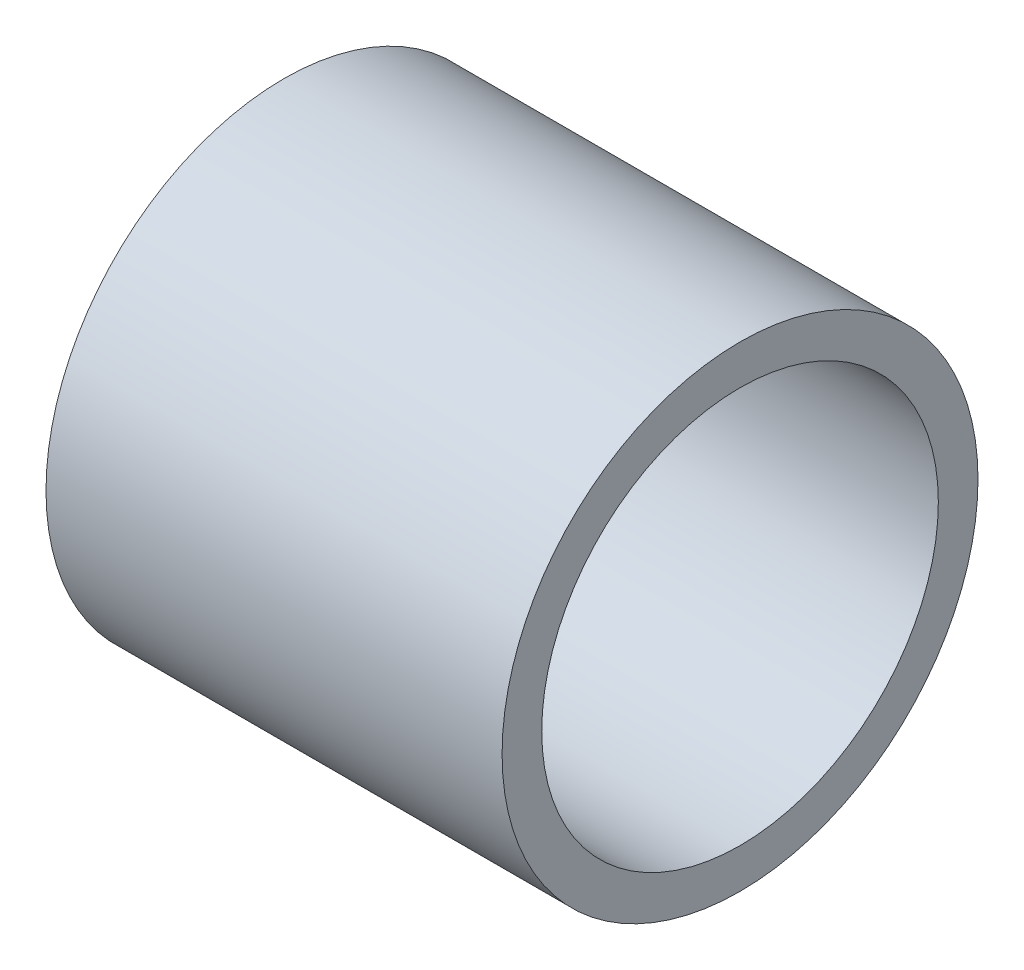
from build123d import *

# Parameters (mm, degrees)
SKETCH_1_R      = 6
EXTRUDE_1_DEPTH = 13
SHELL_1_T       = -1


with BuildPart() as part:
    # 草圖1 → 填料-伸長1 (new body)
    with BuildSketch(Plane(origin=(0, 0, 0), x_dir=(0, 0, -1), z_dir=(1, 0, 0))):
        with Locations(Location((0, 0, 0), (0, 0, 180))):
            Circle(SKETCH_1_R)
    extrude(amount=EXTRUDE_1_DEPTH)

    # 草圖2 → 除料-旋轉2 (revolve, cut)
    with BuildSketch(Plane(origin=(0, 0, 0), x_dir=(1, 0, 0), z_dir=(0, 1, 0)), mode=Mode.PRIVATE) as cut_revolve_2_sk:
        Polygon((0, 0), (1.5, 6), (1.5, 6.496398709), (-0.462606834, 6.496398709), (-0.462606834, 0), align=None)
    revolve(cut_revolve_2_sk.sketch.rotate(Axis((1.002912705, 0, 0), (-1, 0, 0)), 180), axis=Axis((1.002912705, 0, 0), (-1, 0, 0)), mode=Mode.SUBTRACT)

    # 薄殼1
    shell_1_openings = [part.faces().sort_by_distance(p)[0] for p in [
        (13, 0, 0),
    ]]
    offset(amount=SHELL_1_T, openings=shell_1_openings, kind=Kind.INTERSECTION)


solid = part.part
